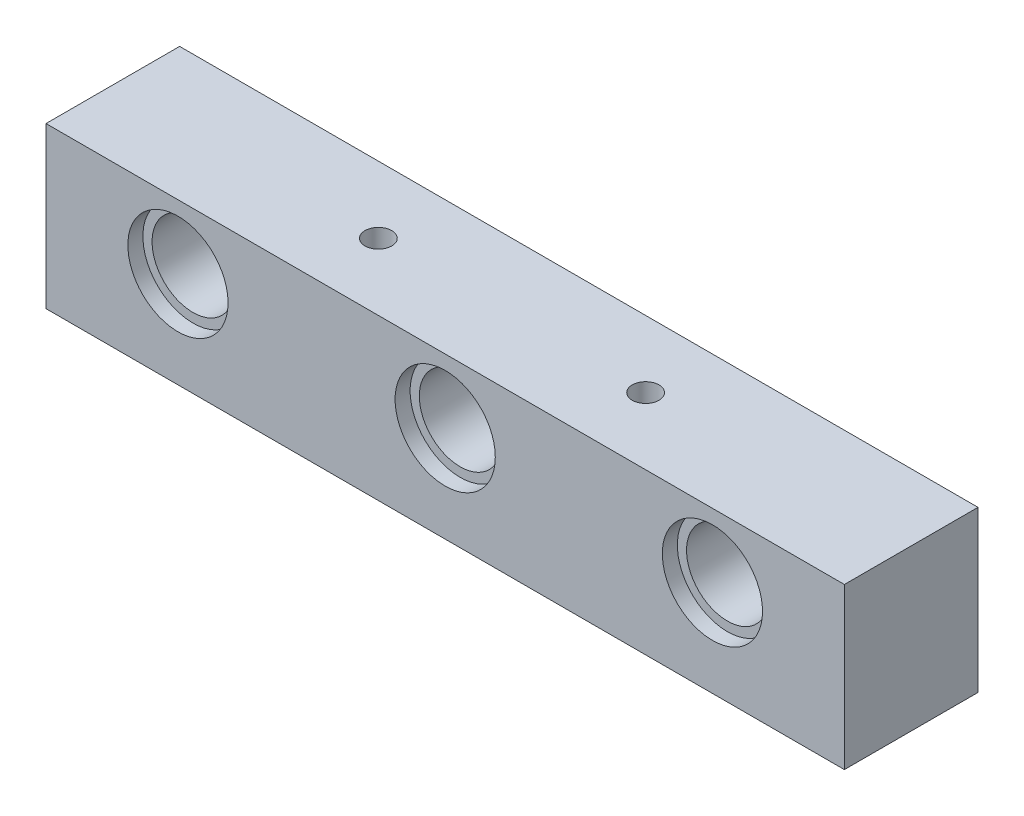
from build123d import *

# Parameters (mm, degrees)
SKIZZE1_W                       = 47.8
SKIZZE1_H                       = 9.6
AUFSATZ_LINEAR_AUSTRAGEN1_DEPTH = 4
SKIZZE2_R                       = 2.45
SCHNITT_LINEAR_AUSTRAGEN1_DEPTH = 26.656383221
SKIZZE2_3_R                     = 3
SKIZZE2_3_R_2                   = 2.45
SCHNITT_LINEAR_AUSTRAGEN2_DEPTH = 0.9
M2_GEWINDEBOHRUNG1_D            = 1.6
SKIZZE5_R                       = 2.45
SCHNITT_LINEAR_AUSTRAGEN3_DEPTH = 2


with BuildPart() as part:
    # Skizze1 → Aufsatz-Linear austragen1 (new, symmetric)
    with BuildSketch(Plane.XY):
        Rectangle(SKIZZE1_W, SKIZZE1_H)
    extrude(amount=AUFSATZ_LINEAR_AUSTRAGEN1_DEPTH, both=True)

    # Skizze2 → Schnitt-Linear austragen1 (cut, through all)
    with BuildSketch(Plane.XY.offset(4)):
        with Locations((-16, 0.95)):
            Circle(SKIZZE2_R)
        with Locations((0, 0.95)):
            Circle(SKIZZE2_R)
        with Locations((16, 0.95)):
            Circle(SKIZZE2_R)
    extrude(amount=-SCHNITT_LINEAR_AUSTRAGEN1_DEPTH, mode=Mode.SUBTRACT)

    # Skizze2_3 → Schnitt-Linear austragen2 (cut)
    # profile 1 of 3: a face of its own
    with BuildSketch(Plane.XY.offset(4)):
        with Locations((-16, 0.95)):
            Circle(SKIZZE2_3_R)
        with Locations((-16, 0.95)):
            Circle(SKIZZE2_3_R_2, mode=Mode.SUBTRACT)
    # profile 2 of 3: a face of its own
    with BuildSketch(Plane.XY.offset(4)):
        with Locations((0, 0.95)):
            Circle(SKIZZE2_3_R)
        with Locations((0, 0.95)):
            Circle(SKIZZE2_3_R_2, mode=Mode.SUBTRACT)
    # profile 3 of 3: a face of its own
    with BuildSketch(Plane.XY.offset(4)):
        with Locations((16, 0.95)):
            Circle(SKIZZE2_3_R)
        with Locations((16, 0.95)):
            Circle(SKIZZE2_3_R_2, mode=Mode.SUBTRACT)
    schnitt_linear_austragen2 = extrude(amount=-SCHNITT_LINEAR_AUSTRAGEN2_DEPTH, mode=Mode.SUBTRACT)

    # Spiegeln1: Schnitt-Linear austragen2 across plane
    add(schnitt_linear_austragen2.mirror(Plane.XY), mode=Mode.SUBTRACT)

    # M2 Gewindebohrung1 (through all)
    with Locations(Plane(origin=(0, -4.8, 0), x_dir=(-1, 0, 0), z_dir=(0, -1, 0))):
        with Locations((-8, 0), (8, 0)):
            Hole(M2_GEWINDEBOHRUNG1_D / 2)

    # Skizze5 → Schnitt-Linear austragen3 (cut)
    with BuildSketch(Plane.XZ.offset(4.8)):
        with Locations((-20, 0)):
            Circle(SKIZZE5_R)
        with Locations((-4, 0)):
            Circle(SKIZZE5_R)
        with Locations((-12, 0)):
            Circle(SKIZZE5_R)
        with Locations((4, 0)):
            Circle(SKIZZE5_R)
        with Locations((12, 0)):
            Circle(SKIZZE5_R)
        with Locations((20, 0)):
            Circle(SKIZZE5_R)
    extrude(amount=-SCHNITT_LINEAR_AUSTRAGEN3_DEPTH, mode=Mode.SUBTRACT)


solid = part.part
